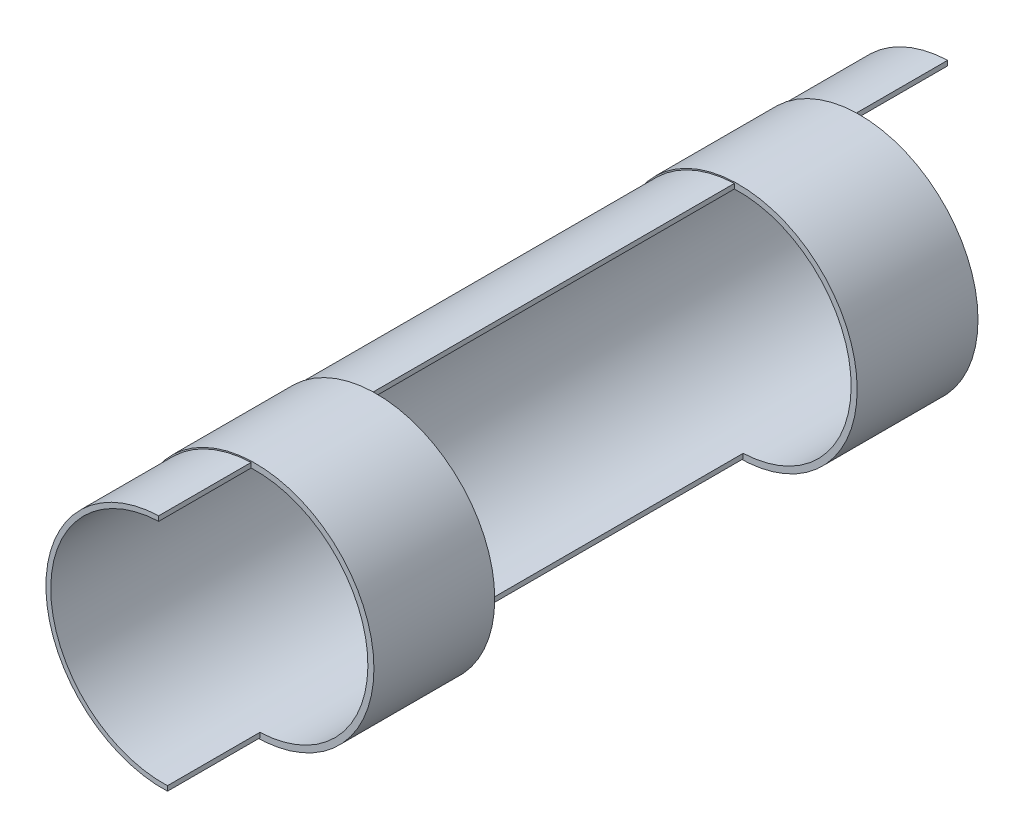
from build123d import *

# Parameters (mm, degrees)
BOSS_EXTRUDE1_DEPTH = 32.65
SKETCH2_R           = 9.8
SKETCH2_R_2         = 9.3
BOSS_EXTRUDE2_DEPTH = 5
LPATTERN1_COUNT     = 2
LPATTERN1_PITCH     = 40


with BuildPart() as part:
    # Sketch1 → Boss-Extrude1 (new body, symmetric)
    with BuildSketch(Plane.XY):
        with BuildLine():
            Line((-0.361769768, 9.693251396), (-0.361769768, 9.292960919))
            ThreePointArc((-0.361769768, 9.292960919), (-9.292960919, -0.361769768), (0.361769768, -9.292960919))
            Line((0.361769768, -9.292960919), (0.361769768, -9.693251396))
            ThreePointArc((0.361769768, -9.693251396), (-9.693251396, -0.361769768), (-0.361769768, 9.693251396))
        make_face()
    extrude(amount=BOSS_EXTRUDE1_DEPTH, both=True)

    # Sketch2 → Boss-Extrude2 (add, symmetric)
    with BuildSketch(Plane.XY.offset(20)):
        Circle(SKETCH2_R)
        Circle(SKETCH2_R_2, mode=Mode.SUBTRACT)
    boss_extrude2 = extrude(amount=BOSS_EXTRUDE2_DEPTH, both=True)

    # LPattern1: Boss-Extrude2 ×2
    with Locations(*[(0, 0, -i * LPATTERN1_PITCH) for i in range(1, LPATTERN1_COUNT)]):
        add(boss_extrude2)


solid = part.part
